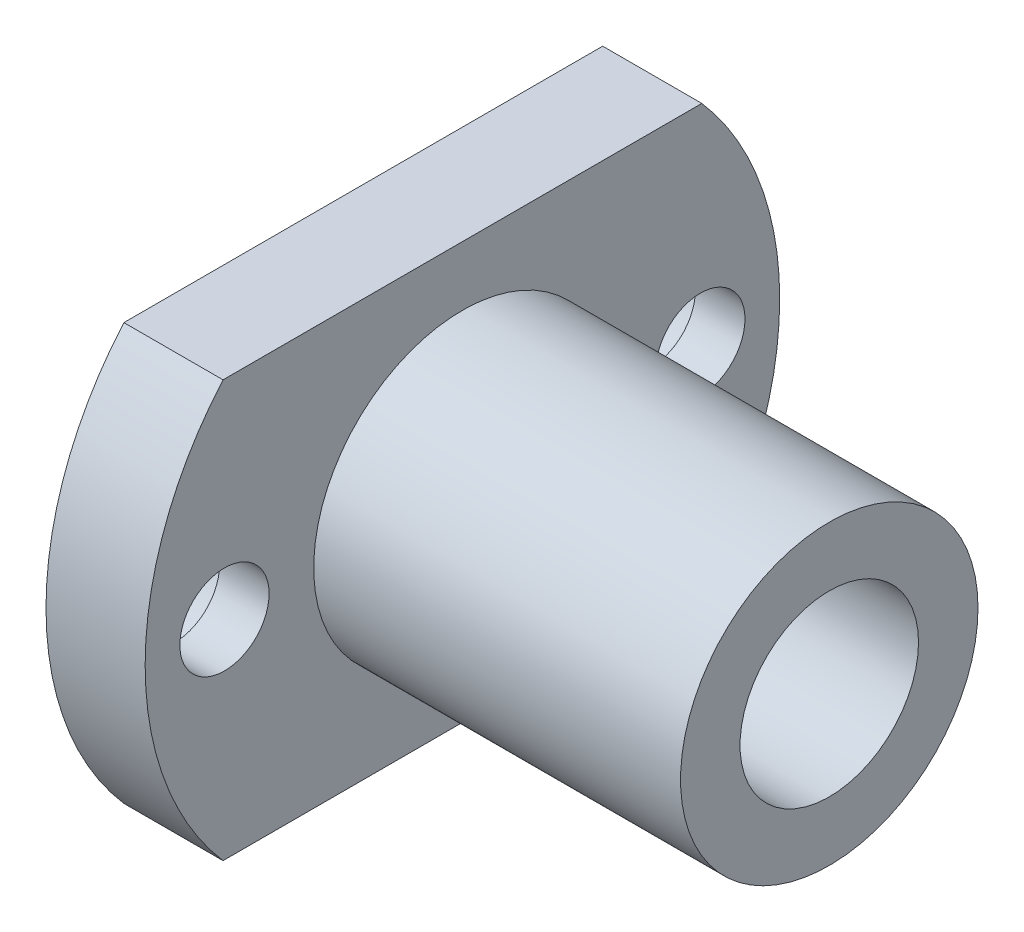
from build123d import *

# Parameters (mm, degrees)
EXTRUDE_3_DEPTH     = 5
SKETCH_3_R          = 2.25
CUT_EXTRUDE_4_DEPTH = 2.5
SKETCH_5_R          = 7.5
EXTRUDE_4_DEPTH     = 18.5
SKETCH_6_R          = 4.5
CUT_EXTRUDE_5_DEPTH = 24.5
SKETCH_7_R          = 3.25
CUT_EXTRUDE_6_DEPTH = 2.5


with BuildPart() as part:
    # 草图1 → 凸台-拉伸3 (new body)
    with BuildSketch(Plane(origin=(0, 0, 0), x_dir=(0, 0, -1), z_dir=(1, 0, 0))):
        with BuildLine():
            Line((-12.072696468, 10.5), (12.072696468, 10.5))
            ThreePointArc((12.072696468, 10.5), (16, 0), (12.072696468, -10.5))
            Line((12.072696468, -10.5), (-12.072696468, -10.5))
            ThreePointArc((-12.072696468, -10.5), (-16, 0), (-12.072696468, 10.5))
        make_face()
    extrude(amount=EXTRUDE_3_DEPTH)

    # 草图3 → 切除-拉伸4 (cut)
    with BuildSketch(Plane(origin=(5, 0, 0), x_dir=(0, 0, -1), z_dir=(1, 0, 0))):
        with Locations((-12, 0)):
            Circle(SKETCH_3_R)
        with Locations((12, 0)):
            Circle(SKETCH_3_R)
    extrude(amount=-CUT_EXTRUDE_4_DEPTH, mode=Mode.SUBTRACT)

    # 草图5 → 凸台-拉伸4 (add)
    with BuildSketch(Plane(origin=(5, 0, 0), x_dir=(0, 0, -1), z_dir=(1, 0, 0))):
        Circle(SKETCH_5_R)
    extrude(amount=EXTRUDE_4_DEPTH)

    # 草图6 → 切除-拉伸5 (cut, through all)
    with BuildSketch(Plane(origin=(23.5, 0, 0), x_dir=(0, 0, -1), z_dir=(1, 0, 0))):
        Circle(SKETCH_6_R)
    extrude(amount=-CUT_EXTRUDE_5_DEPTH, mode=Mode.SUBTRACT)

    # 草图7 → 切除-拉伸6 (cut)
    with BuildSketch(Plane.ZY):
        with Locations((-12, 0)):
            Circle(SKETCH_7_R)
        with Locations((12, 0)):
            Circle(SKETCH_7_R)
    extrude(amount=-CUT_EXTRUDE_6_DEPTH, mode=Mode.SUBTRACT)


solid = part.part
